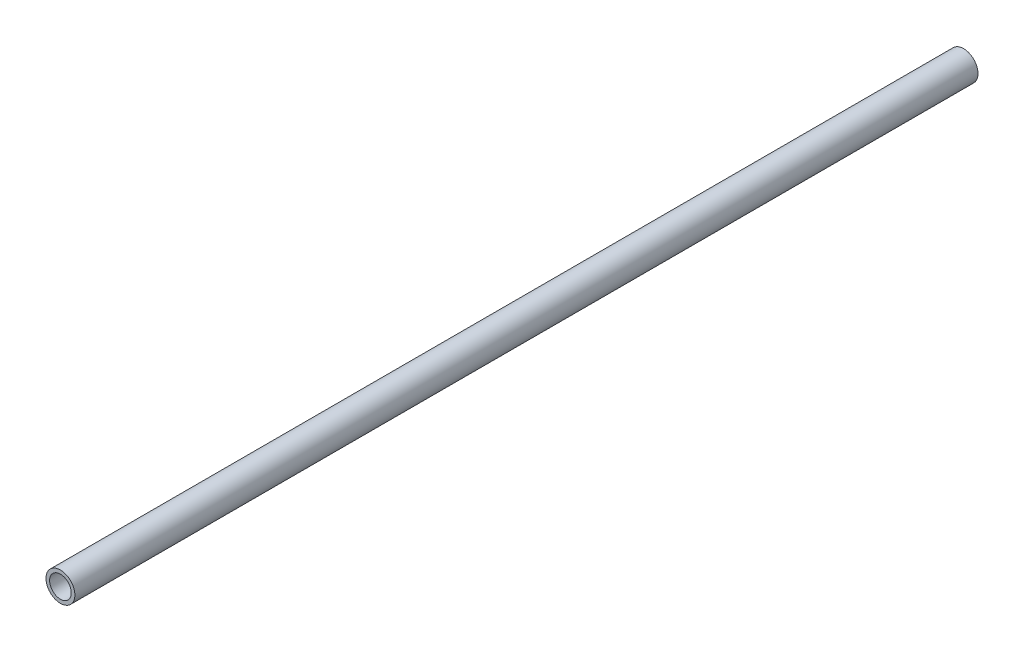
from build123d import *

# Parameters (mm, degrees)
SKETCH_1_R      = 4
SKETCH_1_R_2    = 3
EXTRUDE_1_DEPTH = 250


with BuildPart() as part:
    # 草图1 → 凸台-拉伸1 (new body)
    with BuildSketch(Plane.XY):
        Circle(SKETCH_1_R)
        Circle(SKETCH_1_R_2, mode=Mode.SUBTRACT)
    extrude(amount=EXTRUDE_1_DEPTH)


solid = part.part
